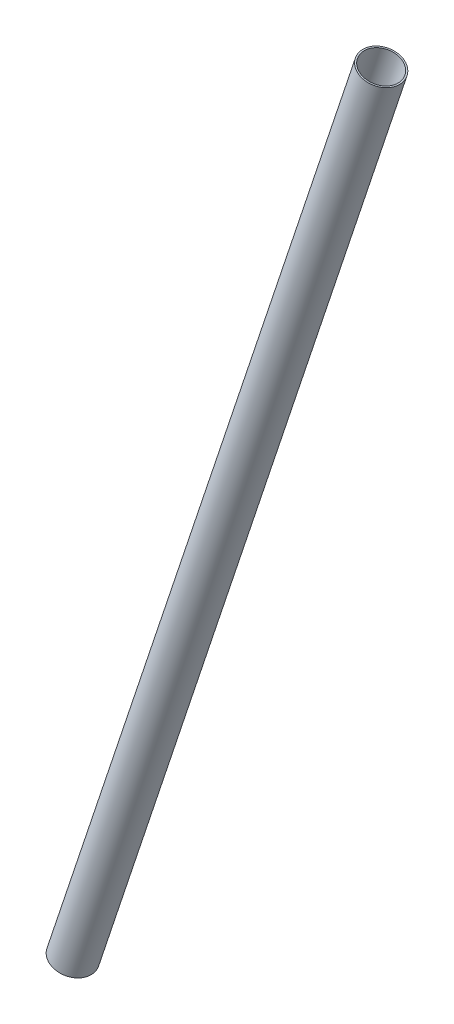
from build123d import *


with BuildPart() as part:
    # Croquis1 → Revolución1 (revolve)
    with BuildSketch(Plane.XY):
        Polygon((426.773950856, 1200), (21.419160685, -16.064370514), (19.521794089, -15.431914982), (424.87658426, 1200.632455532), align=None)
    revolve(axis=Axis((400, 1200, 0), (-0.316227766, -0.948683298, 0)))


solid = part.part
